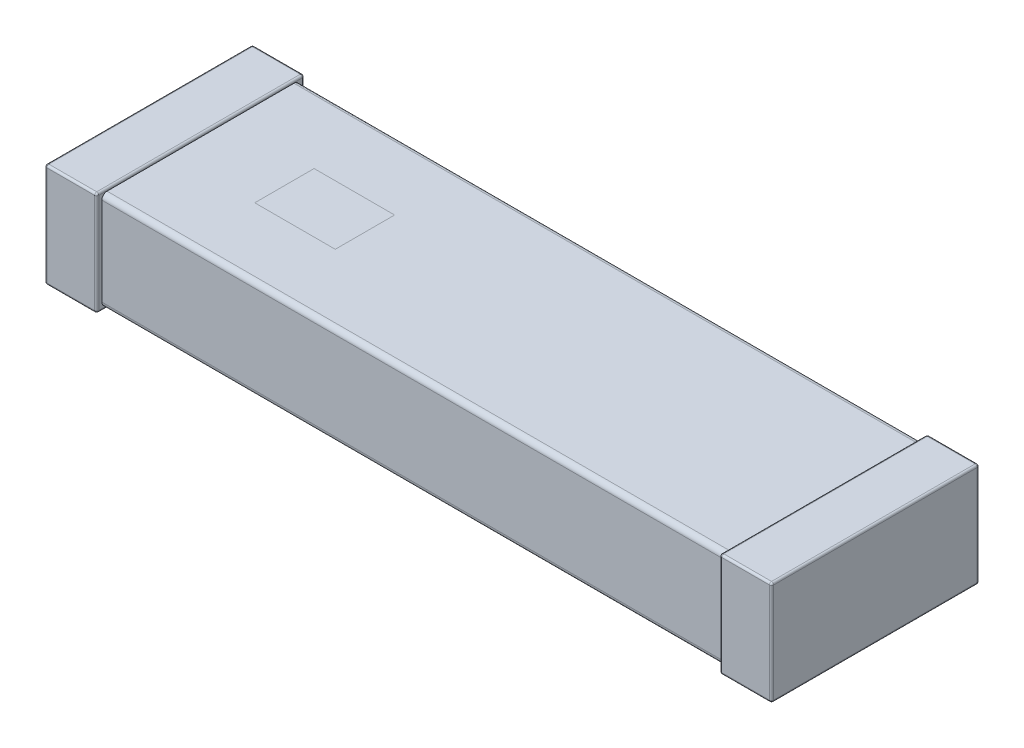
from build123d import *

# Parameters (mm, degrees)
SKIZZE1_W                         = 0.5
SKIZZE1_H                         = 2
AUFSATZ_LINEAR_AUSTRAGEN1_DEPTH   = 1
AUFSATZ_LINEAR_AUSTRAGEN1_2_DEPTH = 1
AUFSATZ_LINEAR_START              = 0.025
SKIZZE1_3_W                       = 6
SKIZZE1_3_H                       = 1.9
AUFSATZ_LINEAR_AUSTRAGEN2_DEPTH   = 0.95
VERRUNDUNG1_R                     = 0.02
VERRUNDUNG3_R                     = 0.02
VERRUNDUNG4_R                     = 0.05


with BuildPart() as part:
    # Skizze1 → Aufsatz-Linear austragen1 (new body)
    with BuildSketch(Plane(origin=(0, 0, 0), x_dir=(1, 0, 0), z_dir=(0, 1, 0))):
        with Locations((-3.25, 0)):
            Rectangle(SKIZZE1_W, SKIZZE1_H)
    extrude(amount=AUFSATZ_LINEAR_AUSTRAGEN1_DEPTH)

    # Verrundung1
    verrundung1_edges = [part.edges().sort_by_distance(p)[0] for p in [
        (-3, 0.5, 1),
        (-3, 1, 0),
        (-3, 0.5, -1),
        (-3, 0, 0),
        (-3.5, 0.5, -1),
        (-3.5, 1, 0),
        (-3.5, 0.5, 1),
        (-3.5, 0, 0),
        (-3.25, 0, -1),
        (-3.25, 1, -1),
        (-3.25, 1, 1),
        (-3.25, 0, 1),
    ]]
    fillet(verrundung1_edges, radius=VERRUNDUNG1_R)


with BuildPart() as body_2:
    # Skizze1 → Aufsatz-Linear austragen1 2 (new body)
    with BuildSketch(Plane(origin=(0, 0, 0), x_dir=(1, 0, 0), z_dir=(0, 1, 0))):
        with Locations((3.25, 0)):
            Rectangle(SKIZZE1_W, SKIZZE1_H)
    extrude(amount=AUFSATZ_LINEAR_AUSTRAGEN1_2_DEPTH)

    # Verrundung3
    verrundung3_edges = [body_2.edges().sort_by_distance(p)[0] for p in [
        (3.25, 0, -1),
        (3, 0.5, -1),
        (3, 0, 0),
        (3, 0.5, 1),
        (3.25, 0, 1),
        (3.25, 1, 1),
        (3, 1, 0),
        (3.25, 1, -1),
        (3.5, 0.5, 1),
        (3.5, 1, 0),
        (3.5, 0.5, -1),
        (3.5, 0, 0),
    ]]
    fillet(verrundung3_edges, radius=VERRUNDUNG3_R)


with BuildPart() as body_3:
    # Skizze1_3 → Aufsatz-Linear austragen2 (new body)
    with BuildSketch(Plane(origin=(0, 0, 0), x_dir=(1, 0, 0), z_dir=(0, 1, 0)).offset(AUFSATZ_LINEAR_START)):
        Rectangle(SKIZZE1_3_W, SKIZZE1_3_H)
    extrude(amount=AUFSATZ_LINEAR_AUSTRAGEN2_DEPTH)

    # Verrundung4
    verrundung4_edges = [body_3.edges().sort_by_distance(p)[0] for p in [
        (0, 0.025, -0.95),
        (0, 0.975, -0.95),
        (0, 0.025, 0.95),
        (0, 0.975, 0.95),
    ]]
    fillet(verrundung4_edges, radius=VERRUNDUNG4_R)


solid = Compound([part.part, body_2.part, body_3.part])
